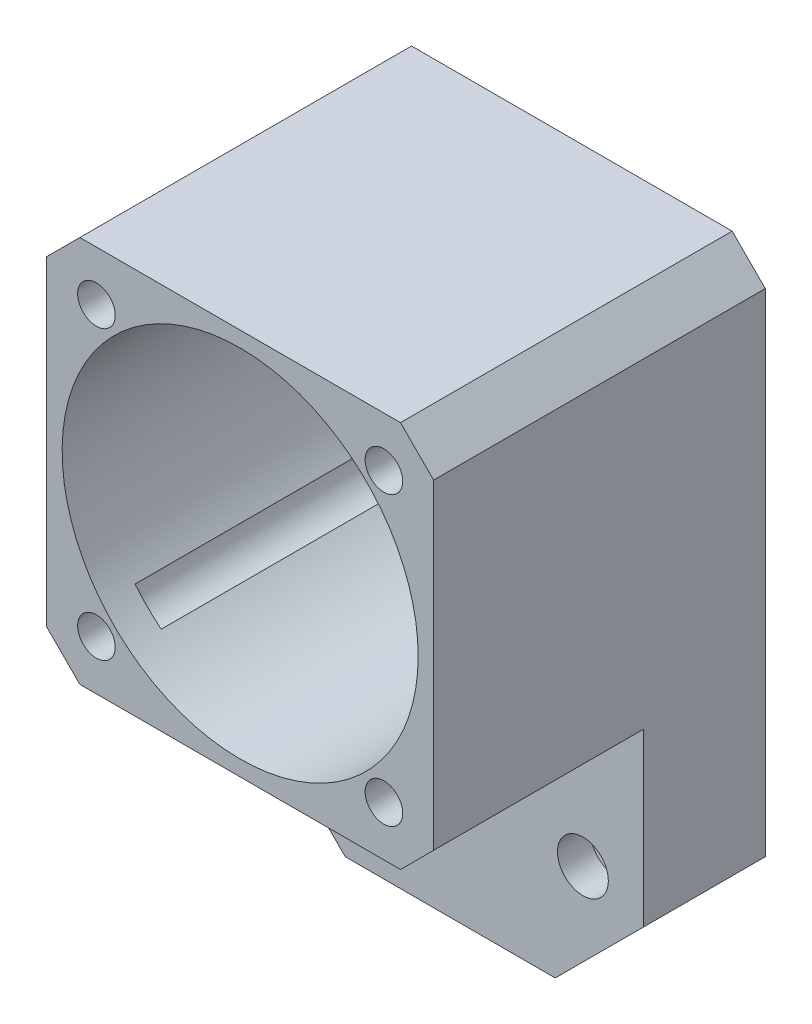
from build123d import *

# Parameters (mm, degrees)
SKIZZE1_W                       = 35
SKIZZE1_H                       = 55.5
SKIZZE1_R                       = 16.1
SKIZZE1_R_2                     = 1.7
SKIZZE1_R_3                     = 2.3
AUFSATZ_LINEAR_AUSTRAGEN1_DEPTH = 11
SKIZZE2_W                       = 35
SKIZZE2_H                       = 35
SKIZZE2_R                       = 16.1
SKIZZE2_R_2                     = 1.7
AUFSATZ_LINEAR_AUSTRAGEN2_DEPTH = 19
SKIZZE4_R                       = 4
SCHNITT_LINEAR_AUSTRAGEN1_DEPTH = 8
SKIZZE5_R                       = 2.9
SCHNITT_LINEAR_AUSTRAGEN2_DEPTH = 27
FASE1_SIZE                      = 3
FASE2_SIZE                      = 8


with BuildPart() as part:
    # Skizze1 → Aufsatz-Linear austragen1 (new body)
    with BuildSketch(Plane.XY):
        with Locations((0, -10.25)):
            Rectangle(SKIZZE1_W, SKIZZE1_H)
        Circle(SKIZZE1_R, mode=Mode.SUBTRACT)
        with Locations((-13, 13)):
            Circle(SKIZZE1_R_2, mode=Mode.SUBTRACT)
        with Locations((13, 13)):
            Circle(SKIZZE1_R_2, mode=Mode.SUBTRACT)
        with Locations((-13, -13)):
            Circle(SKIZZE1_R_2, mode=Mode.SUBTRACT)
        with Locations((13, -13)):
            Circle(SKIZZE1_R_2, mode=Mode.SUBTRACT)
        with Locations((-12, -28)):
            Circle(SKIZZE1_R_3, mode=Mode.SUBTRACT)
        with Locations((12, -28)):
            Circle(SKIZZE1_R_3, mode=Mode.SUBTRACT)
    extrude(amount=AUFSATZ_LINEAR_AUSTRAGEN1_DEPTH)

    # Skizze2 → Aufsatz-Linear austragen2 (add)
    with BuildSketch(Plane.XY.offset(11)):
        Rectangle(SKIZZE2_W, SKIZZE2_H)
        Circle(SKIZZE2_R, mode=Mode.SUBTRACT)
        with Locations((13, 13)):
            Circle(SKIZZE2_R_2, mode=Mode.SUBTRACT)
        with Locations((13, -13)):
            Circle(SKIZZE2_R_2, mode=Mode.SUBTRACT)
        with Locations((-13, -13)):
            Circle(SKIZZE2_R_2, mode=Mode.SUBTRACT)
        with Locations((-13, 13)):
            Circle(SKIZZE2_R_2, mode=Mode.SUBTRACT)
    extrude(amount=AUFSATZ_LINEAR_AUSTRAGEN2_DEPTH)

    # Skizze4 → Schnitt-Linear austragen1 (cut)
    with BuildSketch(Plane.XY):
        with Locations((-12, -28)):
            Circle(SKIZZE4_R)
        with Locations((12, -28)):
            Circle(SKIZZE4_R)
    extrude(amount=SCHNITT_LINEAR_AUSTRAGEN1_DEPTH, mode=Mode.SUBTRACT)

    # Skizze5 → Schnitt-Linear austragen2 (cut)
    with BuildSketch(Plane.XY):
        with Locations((-13, 13)):
            Circle(SKIZZE5_R)
        with Locations((13, 13)):
            Circle(SKIZZE5_R)
        with Locations((-13, -13)):
            Circle(SKIZZE5_R)
        with Locations((13, -13)):
            Circle(SKIZZE5_R)
    extrude(amount=SCHNITT_LINEAR_AUSTRAGEN2_DEPTH, mode=Mode.SUBTRACT)

    # Fase1
    fase1_edges = [part.edges().sort_by_distance(p)[0] for p in [
        (-17.5, -17.5, 20.5),
        (17.5, -17.5, 20.5),
        (-17.5, 17.5, 15),
        (17.5, 17.5, 15),
    ]]
    chamfer(fase1_edges, length=FASE1_SIZE)

    # Fase2
    fase2_edges = [part.edges().sort_by_distance(p)[0] for p in [
        (17.5, -38, 5.5),
        (-17.5, -38, 5.5),
    ]]
    chamfer(fase2_edges, length=FASE2_SIZE)


solid = part.part
